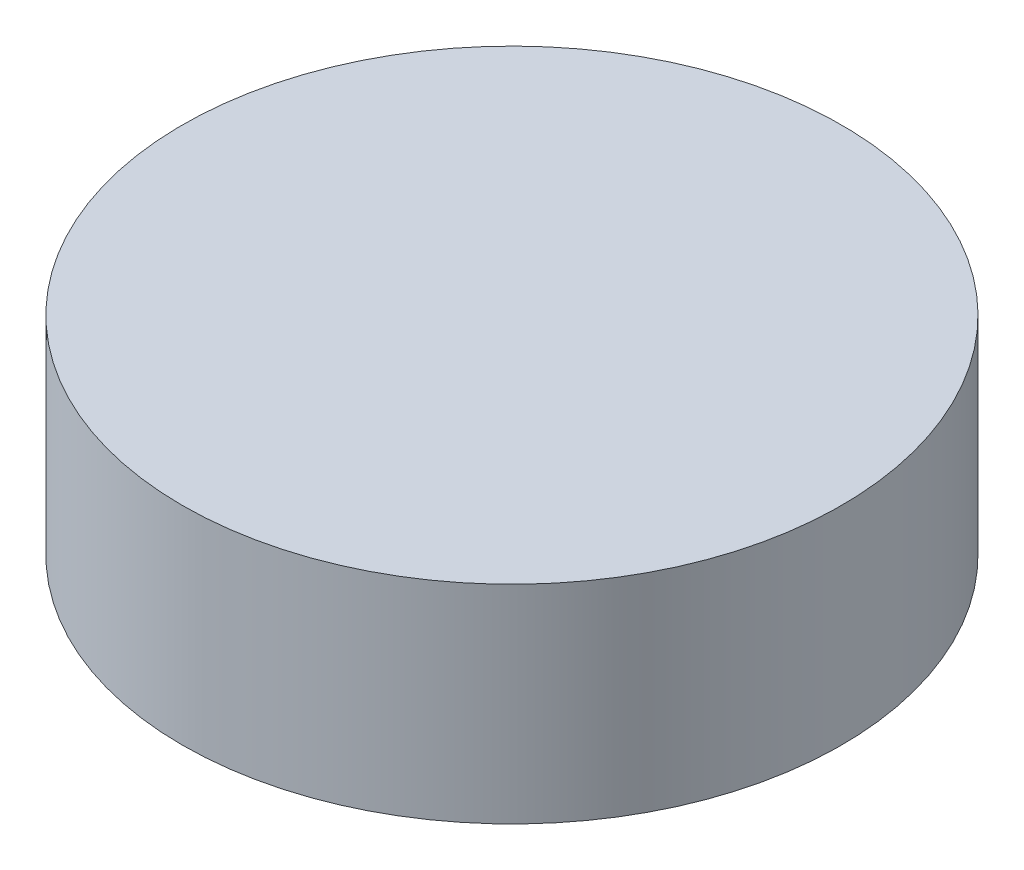
from build123d import *

# Parameters (mm, degrees)
SKETCH1_R           = 6.35
BOSS_EXTRUDE1_DEPTH = 4
SKETCH2_R           = 1
CUT_EXTRUDE2_DEPTH  = 1
SKETCH2_3_R         = 4.2
SKETCH2_3_R_2       = 1
CUT_EXTRUDE3_DEPTH  = 1


with BuildPart() as part:
    # Sketch1 → Boss-Extrude1 (new body)
    with BuildSketch(Plane(origin=(0, 0, 0), x_dir=(1, 0, 0), z_dir=(0, 1, 0))):
        Circle(SKETCH1_R)
    extrude(amount=BOSS_EXTRUDE1_DEPTH)

    # Sketch2 → Cut-Extrude2 (cut)
    with BuildSketch(Plane.XZ):
        with Locations((0, -4.2)):
            Circle(SKETCH2_R)
    extrude(amount=-CUT_EXTRUDE2_DEPTH, mode=Mode.SUBTRACT)

    # Sketch2_3 → Cut-Extrude3 (cut)
    with BuildSketch(Plane.XZ):
        Circle(SKETCH2_3_R)
        with Locations((0, 4.2)):
            Circle(SKETCH2_3_R_2)
    extrude(amount=-CUT_EXTRUDE3_DEPTH, mode=Mode.SUBTRACT)


solid = part.part
